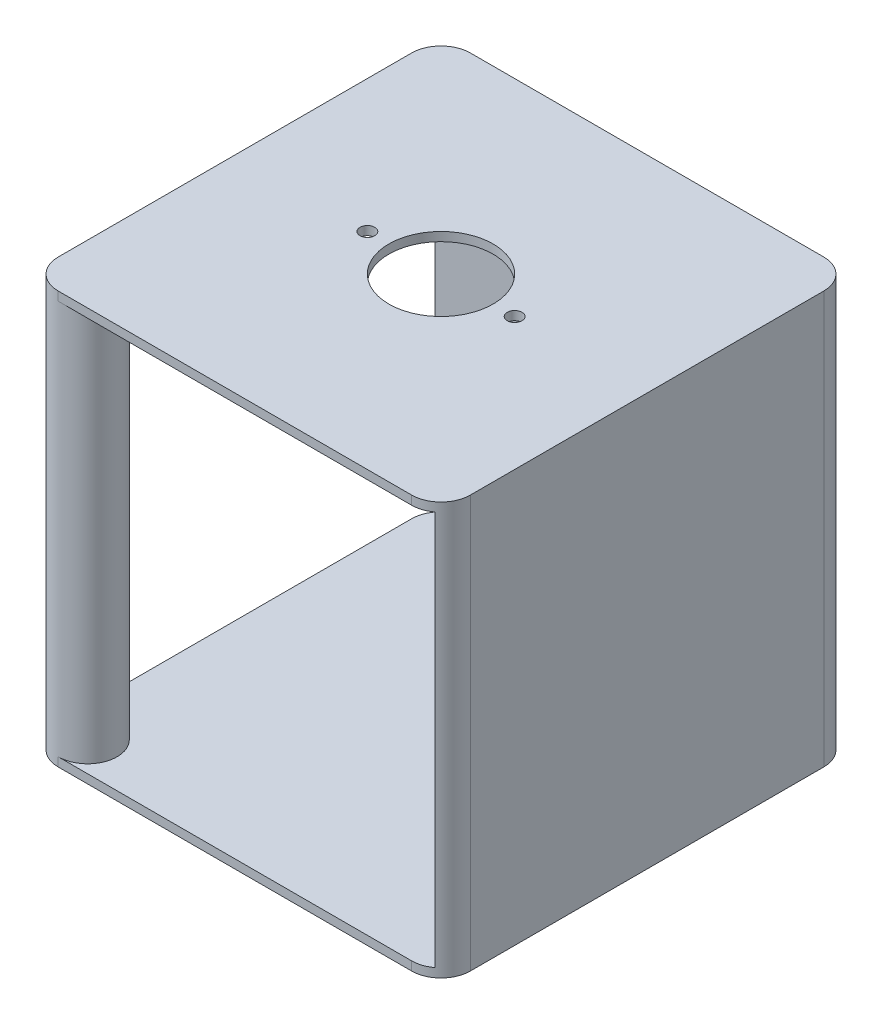
from build123d import *
from build123d.topology import SkipClean

# Parameters (mm, degrees)
BOSS_EXTRUDE3_DEPTH = 1.905
BOSS_EXTRUDE4_START = -86.995
BOSS_EXTRUDE4_DEPTH = 86.995
CUT_EXTRUDE2_DEPTH  = 85.09
SKETCH16_W          = 82.55
SKETCH16_H          = 85.09
CUT_EXTRUDE3_DEPTH  = 86.36
SKETCH18_W          = 80.01
SKETCH18_H          = 85.09
CUT_EXTRUDE4_DEPTH  = 86.36
SKETCH19_R          = 6.35
BOSS_EXTRUDE5_DEPTH = 86.36
CUT_EXTRUDE5_REACH  = 110.88
SKETCH20_R          = 11.2395
SKETCH20_R_2        = 1.5875


with BuildPart() as part:
    # Sketch7 → Boss-Extrude3 (new body)
    with BuildSketch(Plane(origin=(0, 0, 0), x_dir=(1, 0, 0), z_dir=(0, 1, 0))):
        with BuildLine():
            Line((-38.1, 44.45), (38.1, 44.45))
            ThreePointArc((38.1, 44.45), (42.590128061, 42.590128061), (44.45, 38.1))
            Line((44.45, 38.1), (44.45, -38.1))
            ThreePointArc((44.45, -38.1), (42.590128061, -42.590128061), (38.1, -44.45))
            Line((38.1, -44.45), (-38.1, -44.45))
            ThreePointArc((-38.1, -44.45), (-42.590128061, -42.590128061), (-44.45, -38.1))
            Line((-44.45, -38.1), (-44.45, 38.1))
            ThreePointArc((-44.45, 38.1), (-42.590128061, 42.590128061), (-38.1, 44.45))
        make_face()
    extrude(amount=BOSS_EXTRUDE3_DEPTH)

    # Sketch7_2 → Boss-Extrude4 (add)
    with BuildSketch(Plane(origin=(0, 0, 0), x_dir=(1, 0, 0), z_dir=(0, 1, 0)).offset(BOSS_EXTRUDE4_START)):
        with BuildLine():
            Line((-38.1, 44.45), (38.1, 44.45))
            ThreePointArc((38.1, 44.45), (42.590128061, 42.590128061), (44.45, 38.1))
            Line((44.45, 38.1), (44.45, -38.1))
            ThreePointArc((44.45, -38.1), (42.590128061, -42.590128061), (38.1, -44.45))
            Line((38.1, -44.45), (-38.1, -44.45))
            ThreePointArc((-38.1, -44.45), (-42.590128061, -42.590128061), (-44.45, -38.1))
            Line((-44.45, -38.1), (-44.45, 38.1))
            ThreePointArc((-44.45, 38.1), (-42.590128061, 42.590128061), (-38.1, 44.45))
        make_face()
    extrude(amount=BOSS_EXTRUDE4_DEPTH)

    # Sketch15 → Cut-Extrude2 (cut)
    with BuildSketch(Plane(origin=(0, 0, 0), x_dir=(1, 0, 0), z_dir=(0, 1, 0))):
        with BuildLine():
            Line((-35.56, 41.91), (35.56, 41.91))
            ThreePointArc((35.56, 41.91), (40.050128061, 40.050128061), (41.91, 35.56))
            Line((41.91, 35.56), (41.91, -35.56))
            ThreePointArc((41.91, -35.56), (40.050128061, -40.050128061), (35.56, -41.91))
            Line((35.56, -41.91), (-35.56, -41.91))
            ThreePointArc((-35.56, -41.91), (-40.050128061, -40.050128061), (-41.91, -35.56))
            Line((-41.91, -35.56), (-41.91, 35.56))
            ThreePointArc((-41.91, 35.56), (-40.050128061, 40.050128061), (-35.56, 41.91))
        make_face()
    extrude(amount=-CUT_EXTRUDE2_DEPTH, mode=Mode.SUBTRACT)

    # Sketch16 → Cut-Extrude3 (cut)
    with BuildSketch(Plane.XY.offset(44.45)):
        with Locations((-3.175, -42.545)):
            Rectangle(SKETCH16_W, SKETCH16_H)
    extrude(amount=-CUT_EXTRUDE3_DEPTH, mode=Mode.SUBTRACT)

    # Sketch18 → Cut-Extrude4 (cut)
    with BuildSketch(Plane.ZY.offset(-41.91)):
        with Locations((4.445, -42.545)):
            Rectangle(SKETCH18_W, SKETCH18_H)
    extrude(amount=CUT_EXTRUDE4_DEPTH, mode=Mode.SUBTRACT)

    # Sketch19 → Boss-Extrude5 (add)
    with SkipClean():  # the faces are left unmerged after this step: merging them gives an invalid solid
        with BuildSketch(Plane(origin=(0, -85.09, 0), x_dir=(1, 0, 0), z_dir=(0, 1, 0))):
            with Locations((-38.1, -38.1)):
                Circle(SKETCH19_R)
        extrude(amount=BOSS_EXTRUDE5_DEPTH)

    # Sketch20 → Cut-Extrude5 (cut, up to next)
    with BuildSketch(Plane(origin=(0, 1.905, 0), x_dir=(1, 0, 0), z_dir=(0, 1, 0)), mode=Mode.PRIVATE) as cut_extrude5_sk1:
        Circle(SKETCH20_R)
    cut_extrude5_tool1 = extrude(cut_extrude5_sk1.sketch, amount=-CUT_EXTRUDE5_REACH, mode=Mode.PRIVATE) & part.part
    # Sketch20 → Cut-Extrude5 (cut, up to next)
    with BuildSketch(Plane(origin=(0, 1.905, 0), x_dir=(1, 0, 0), z_dir=(0, 1, 0)), mode=Mode.PRIVATE) as cut_extrude5_sk2:
        with Locations((-15.875, 0)):
            Circle(SKETCH20_R_2)
    cut_extrude5_tool2 = extrude(cut_extrude5_sk2.sketch, amount=-CUT_EXTRUDE5_REACH, mode=Mode.PRIVATE) & part.part
    # Sketch20 → Cut-Extrude5 (cut, up to next)
    with BuildSketch(Plane(origin=(0, 1.905, 0), x_dir=(1, 0, 0), z_dir=(0, 1, 0)), mode=Mode.PRIVATE) as cut_extrude5_sk3:
        with Locations((15.875, 0)):
            Circle(SKETCH20_R_2)
    cut_extrude5_tool3 = extrude(cut_extrude5_sk3.sketch, amount=-CUT_EXTRUDE5_REACH, mode=Mode.PRIVATE) & part.part
    add(cut_extrude5_tool1.solids().sort_by_distance((0, 1.905, 0))[0], mode=Mode.SUBTRACT)
    add(cut_extrude5_tool2.solids().sort_by_distance((-15.875, 1.905, 0))[0], mode=Mode.SUBTRACT)
    add(cut_extrude5_tool3.solids().sort_by_distance((15.875, 1.905, 0))[0], mode=Mode.SUBTRACT)


solid = part.part
